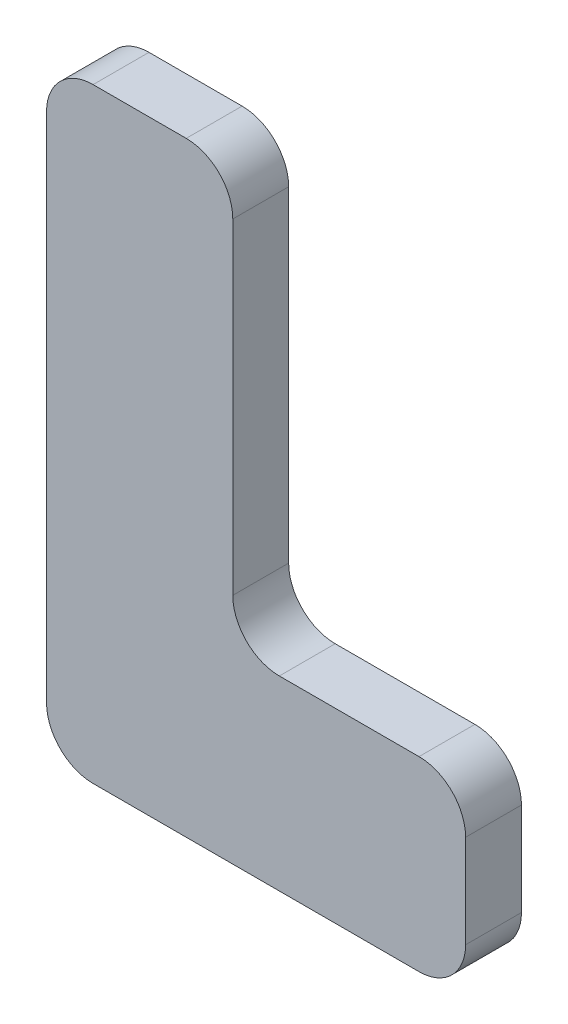
from build123d import *

# Parameters (mm, degrees)
BOSS_EXTRUDE1_DEPTH = 12


with BuildPart() as part:
    # Sketch1 → Boss-Extrude1 (new body)
    with BuildSketch(Plane.XY):
        with BuildLine():
            Line((-107.530862422, 110.302172802), (-107.530862422, 0.302172802))
            ThreePointArc((-107.530862422, 0.302172802), (-104.601930234, -6.768895009), (-97.530862422, -9.697827198))
            Line((-97.530862422, -9.697827198), (-27.530862422, -9.697827198))
            ThreePointArc((-27.530862422, -9.697827198), (-20.45979461, -6.768895009), (-17.530862422, 0.302172802))
            Line((-17.530862422, 0.302172802), (-17.530862422, 20.302172802))
            ThreePointArc((-17.530862422, 20.302172802), (-20.45979461, 27.373240614), (-27.530862422, 30.302172802))
            Line((-27.530862422, 30.302172802), (-57.530862422, 30.302172802))
            ThreePointArc((-57.530862422, 30.302172802), (-64.601930234, 33.231104991), (-67.530862422, 40.302172802))
            Line((-67.530862422, 40.302172802), (-67.530862422, 110.302172802))
            ThreePointArc((-67.530862422, 110.302172802), (-70.45979461, 117.373240614), (-77.530862422, 120.302172802))
            Line((-77.530862422, 120.302172802), (-97.530862422, 120.302172802))
            ThreePointArc((-97.530862422, 120.302172802), (-104.601930234, 117.373240614), (-107.530862422, 110.302172802))
        make_face()
    extrude(amount=BOSS_EXTRUDE1_DEPTH)


solid = part.part
